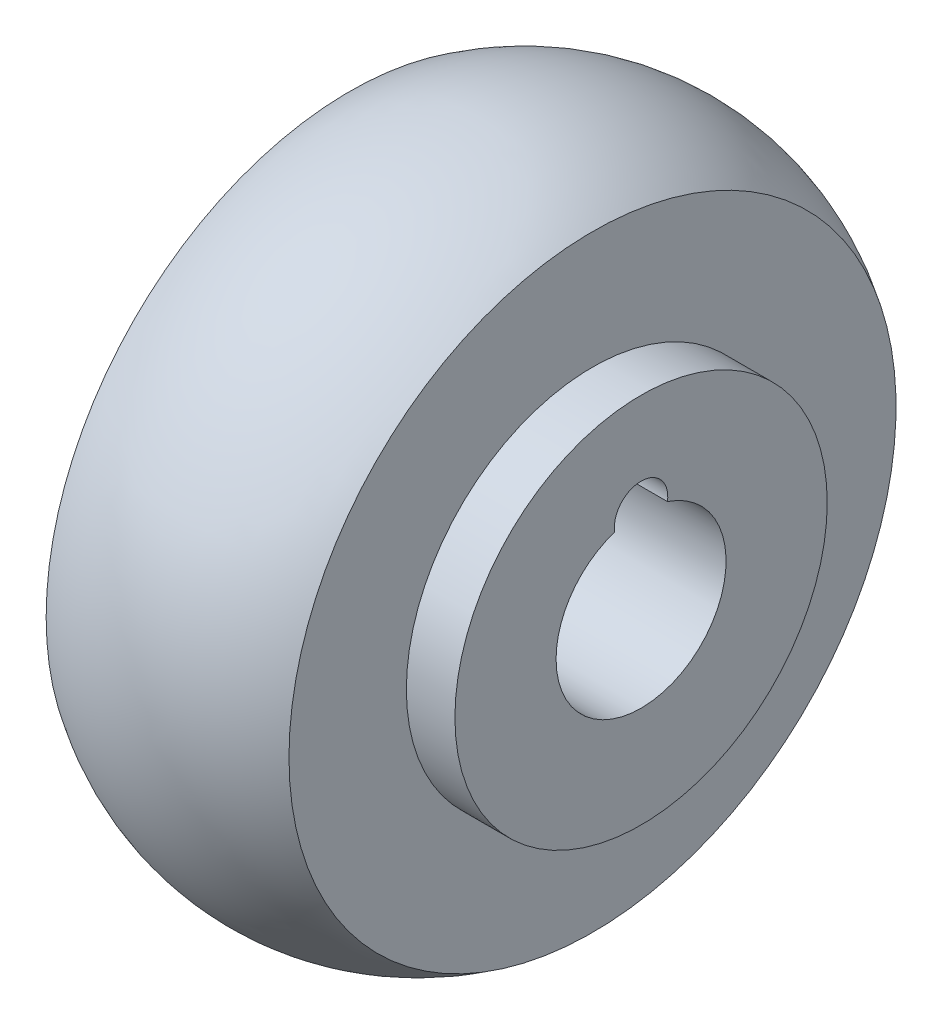
from build123d import *

# Parameters (mm, degrees)
M6_CLEARANCE_HOLE1_D     = 6.6
M6_CLEARANCE_HOLE1_DEPTH = 12


with BuildPart() as part:
    # Sketch1 → Revolve1 (revolve)
    with BuildSketch(Plane(origin=(0, 0, 0), x_dir=(1, 0, 0), z_dir=(0, 1, 0))):
        with BuildLine():
            Line((-21, 10.5), (21, 10.5))
            Line((21, 10.5), (21, 23))
            Line((21, 23), (15, 23))
            Line((15, 23), (15, 37.5))
            ThreePointArc((15, 37.5), (0, 42), (-15, 37.5))
            Line((-15, 37.5), (-15, 23))
            Line((-15, 23), (-21, 23))
            Line((-21, 23), (-21, 10.5))
        make_face()
    revolve(axis=Axis((-68.247922762, 0, 0), (1, 0, 0)))

    # M6 Clearance Hole1
    with Locations(Plane(origin=(21, 10.5, 0), x_dir=(0, 0, 1), z_dir=(1, 0, 0))):
        with Locations((0, 0)):
            Hole(M6_CLEARANCE_HOLE1_D / 2, depth=M6_CLEARANCE_HOLE1_DEPTH)


solid = part.part
